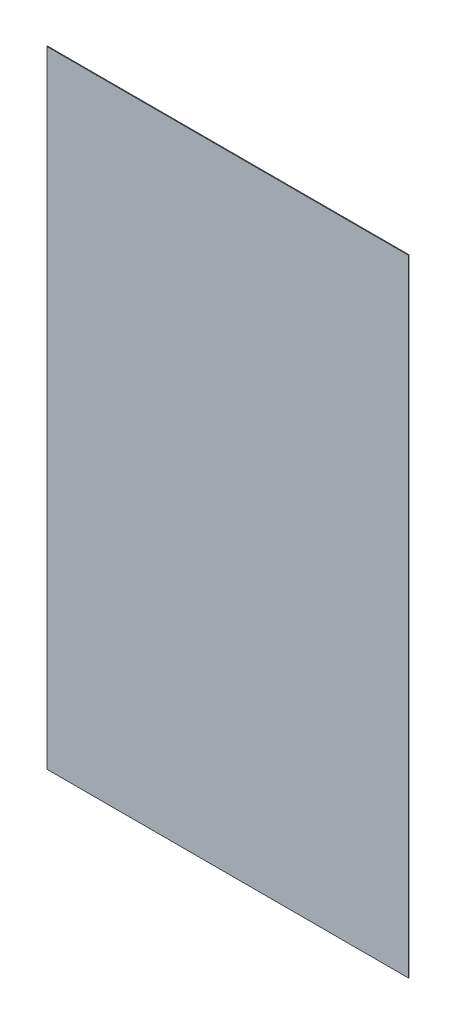
from build123d import *

# Parameters (mm, degrees)
SKETCH1_W           = 406.5
SKETCH1_H           = 703.5
BOSS_EXTRUDE1_DEPTH = 0.85


with BuildPart() as part:
    # Sketch1 → Boss-Extrude1 (new body)
    with BuildSketch(Plane.XY):
        Rectangle(SKETCH1_W, SKETCH1_H)
    extrude(amount=BOSS_EXTRUDE1_DEPTH)


solid = part.part
